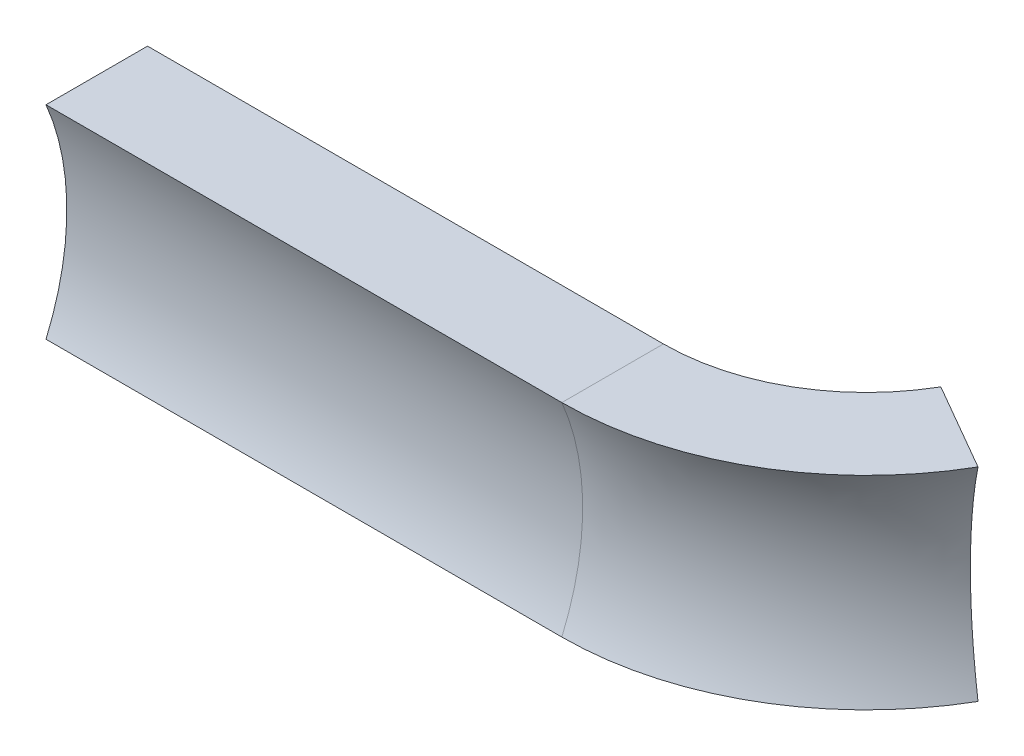
from build123d import *


with BuildPart() as part:
    # Sweep1: sweep along a path in Sketch1
    with BuildLine(Plane(origin=(0, 0, 0), x_dir=(1, 0, 0), z_dir=(0, 1, 0))) as sweep1_path:
        Line((0, 0), (25.4, 0))
        ThreePointArc((25.4, 0), (30.4, 1.339745962), (34.060254038, 5))
    # Sketch2 → Sweep1 (sweep)
    with BuildSketch(Plane(origin=(0, 0, 0), x_dir=(0, 0, -1), z_dir=(1, 0, 0))):
        with BuildLine():
            Line((0, 5), (0, -5))
            Line((0, -5), (-5, -5))
            ThreePointArc((-5, -5), (-3.974330816, 0), (-5, 5))
            Line((-5, 5), (0, 5))
        make_face()
    sweep(path=sweep1_path.line)


solid = part.part
